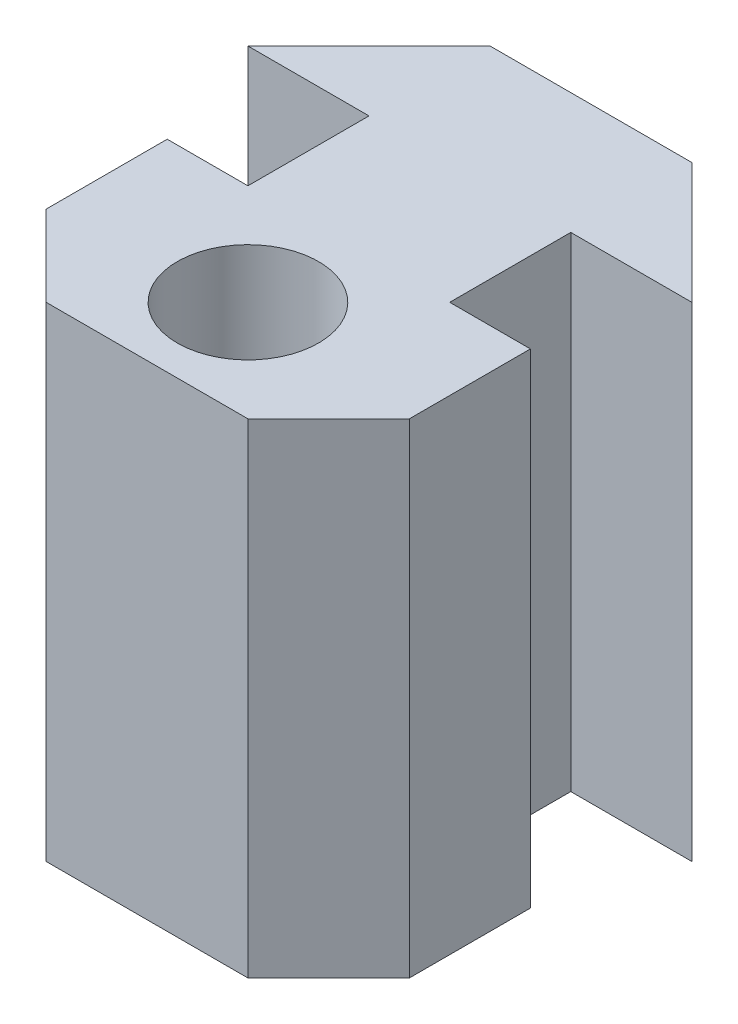
from build123d import *

# Parameters (mm, degrees)
ESQUISSE1_R        = 1.75
BOSS_EXTRU_1_DEPTH = 12
CHANFREIN1_SIZE    = 2


with BuildPart() as part:
    # Esquisse1 → Boss.-Extru.1 (new body)
    with BuildSketch(Plane(origin=(0, 0, 0), x_dir=(-1, 0, 0), z_dir=(0, 1, 0))):
        Polygon((-5.5, 3), (-2.5, 0), (2.5, 0), (5.5, 3), (2.5, 3), (2.5, 6), (4.5, 6), (4.5, 11), (-4.5, 11), (-4.5, 6), (-2.5, 6), (-2.5, 3), align=None)
        with Locations((0, 8.5)):
            Circle(ESQUISSE1_R, mode=Mode.SUBTRACT)
    extrude(amount=BOSS_EXTRU_1_DEPTH)

    # Chanfrein1
    chanfrein1_edges = [part.edges().sort_by_distance(p)[0] for p in [
        (4.5, 6, 11),
        (-4.5, 6, 11),
    ]]
    chamfer(chanfrein1_edges, length=CHANFREIN1_SIZE)


solid = part.part
